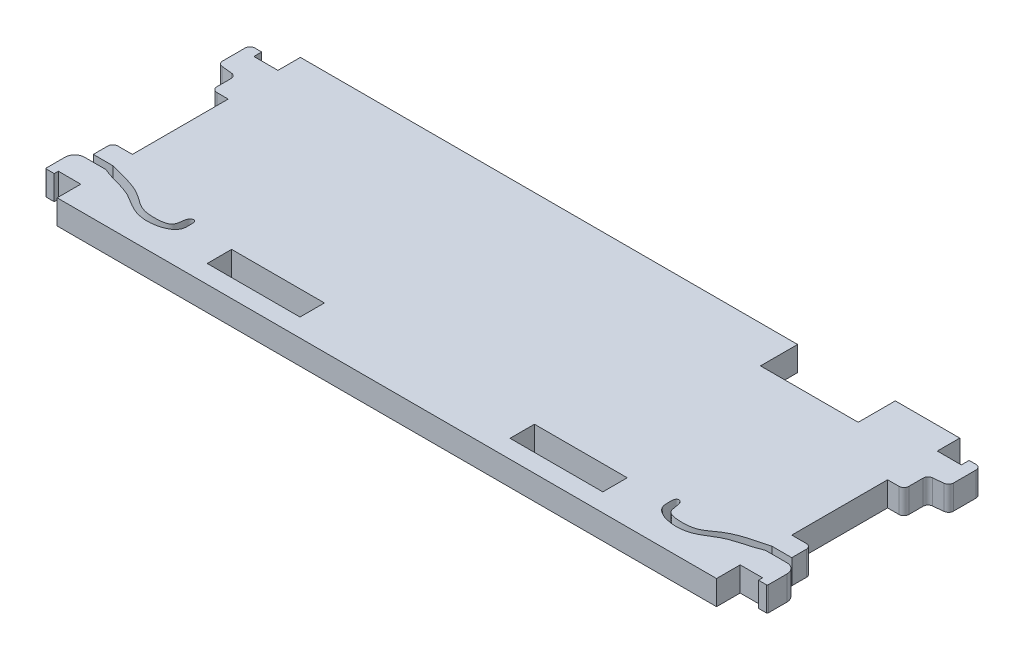
from build123d import *

# Parameters (mm, degrees)
SKETCH1_W           = 12.065
SKETCH1_H           = 3.175
BOSS_EXTRUDE1_DEPTH = 3.175


with BuildPart() as part:
    # Sketch1 → Boss-Extrude1 (new body)
    with BuildSketch(Plane(origin=(0, 0, 0), x_dir=(1, 0, 0), z_dir=(0, 1, 0))):
        with BuildLine():
            Line((34.4805, 15.8115), (34.4805, 10.9855))
            Line((34.4805, 10.9855), (21.7805, 10.9855))
            Line((21.7805, 10.9855), (21.7805, 15.8115))
            Line((21.7805, 15.8115), (-42.8625, 15.8115))
            Line((-42.8625, 15.8115), (-42.8625, 12.8905))
            Line((-42.8625, 12.8905), (-45.9867, 12.8905))
            Line((-45.9867, 12.8905), (-45.9867, 13.9065))
            Line((-45.9867, 13.9065), (-46.8757, 13.9065))
            ThreePointArc((-46.8757, 13.9065), (-47.324712806, 13.720512806), (-47.5107, 13.2715))
            Line((-47.5107, 13.2715), (-47.5107, 10.338056568))
            ThreePointArc((-47.5107, 10.338056568), (-47.347596964, 9.913158633), (-46.942075574, 9.706535165))
            Line((-46.942075574, 9.706535165), (-45.553238812, 9.560562539))
            ThreePointArc((-45.553238812, 9.560562539), (-45.147717422, 9.35393907), (-44.984614386, 8.929041135))
            Line((-44.984614386, 8.929041135), (-44.984614386, 7.062397703))
            ThreePointArc((-44.984614386, 7.062397703), (-44.798627192, 6.613384897), (-44.349614386, 6.427397703))
            Line((-44.349614386, 6.427397703), (-42.8625, 6.427397703))
            Line((-42.8625, 6.427397703), (-42.8625, -6.0325))
            Line((-42.8625, -6.0325), (-44.7675, -6.0325))
            ThreePointArc((-44.7675, -6.0325), (-45.216512806, -6.218487194), (-45.4025, -6.6675))
            Line((-45.4025, -6.6675), (-45.4025, -8.5725))
            Line((-45.4025, -8.5725), (-42.8625, -8.5725))
            add(Edge.make_bspline(
                [(-42.8625, -8.5725), (-41.235514661, -9.036919587), (-38.768416682, -9.43100007), (-36.286434981, -11.615283006), (-34.311523372, -11.820880416), (-32.159465718, -11.562671007), (-32.151870508, -10.227095557), (-31.90154009, -9.420959036), (-31.216693805, -9.360673169), (-31.153771417, -10.339051438), (-31.185927723, -11.920214415), (-33.996921582, -12.842750973), (-36.567382688, -12.305365627), (-39.155382597, -10.334194407), (-41.513606262, -10.077437392), (-42.8625, -9.4615)],
                knots=[0, 0, 0, 0, 0.185038788, 0.2600373, 0.34076905, 0.405570103, 0.445762007, 0.473510944, 0.483382171, 0.508842392, 0.552839679, 0.658674645, 0.754662587, 0.839418999, 1, 1, 1, 1], degree=3))
            Line((-42.8625, -9.4615), (-45.298270377, -9.4615))
            Line((-45.298270377, -9.4615), (-45.6565, -9.4615))
            ThreePointArc((-45.6565, -9.4615), (-46.554525612, -9.833474388), (-46.9265, -10.7315))
            Line((-46.9265, -10.7315), (-46.9265, -13.1445))
            ThreePointArc((-46.9265, -13.1445), (-46.889302561, -13.234302561), (-46.7995, -13.2715))
            Line((-46.7995, -13.2715), (-45.7835, -13.2715))
            Line((-45.7835, -13.2715), (-45.7835, -12.7381))
            Line((-45.7835, -12.7381), (-42.8625, -12.7381))
            Line((-42.8625, -12.7381), (-42.8625, -15.8115))
            Line((-42.8625, -15.8115), (42.8625, -15.8115))
            Line((42.8625, -15.8115), (42.8625, -12.7381))
            Line((42.8625, -12.7381), (45.7835, -12.7381))
            Line((45.7835, -12.7381), (45.7835, -13.2715))
            Line((45.7835, -13.2715), (46.7995, -13.2715))
            ThreePointArc((46.7995, -13.2715), (46.889302561, -13.234302561), (46.9265, -13.1445))
            Line((46.9265, -13.1445), (46.9265, -10.7315))
            ThreePointArc((46.9265, -10.7315), (46.554525612, -9.833474388), (45.6565, -9.4615))
            Line((45.6565, -9.4615), (45.298270377, -9.4615))
            Line((45.298270377, -9.4615), (42.8625, -9.4615))
            add(Edge.make_bspline(
                [(42.8625, -8.5725), (41.235514661, -9.036919587), (38.768416682, -9.43100007), (36.286434981, -11.615283006), (34.311523372, -11.820880416), (32.159465718, -11.562671007), (32.151870508, -10.227095557), (31.90154009, -9.420959036), (31.216693805, -9.360673169), (31.153771417, -10.339051438), (31.185927723, -11.920214415), (33.996921582, -12.842750973), (36.567382688, -12.305365627), (39.155382597, -10.334194407), (41.513606262, -10.077437392), (42.8625, -9.4615)],
                knots=[0, 0, 0, 0, 0.185038788, 0.2600373, 0.34076905, 0.405570103, 0.445762007, 0.473510944, 0.483382171, 0.508842392, 0.552839679, 0.658674645, 0.754662587, 0.839418999, 1, 1, 1, 1], degree=3))
            Line((42.8625, -8.5725), (45.4025, -8.5725))
            Line((45.4025, -8.5725), (45.4025, -6.6675))
            ThreePointArc((45.4025, -6.6675), (45.216512806, -6.218487194), (44.7675, -6.0325))
            Line((44.7675, -6.0325), (42.8625, -6.0325))
            Line((42.8625, -6.0325), (42.8625, 6.427397703))
            Line((42.8625, 6.427397703), (44.349614386, 6.427397703))
            ThreePointArc((44.349614386, 6.427397703), (44.798627192, 6.613384897), (44.984614386, 7.062397703))
            Line((44.984614386, 7.062397703), (44.984614386, 8.929041135))
            ThreePointArc((44.984614386, 8.929041135), (45.147717422, 9.35393907), (45.553238812, 9.560562539))
            Line((45.553238812, 9.560562539), (46.942075574, 9.706535165))
            ThreePointArc((46.942075574, 9.706535165), (47.347596964, 9.913158633), (47.5107, 10.338056568))
            Line((47.5107, 10.338056568), (47.5107, 13.2715))
            ThreePointArc((47.5107, 13.2715), (47.324712806, 13.720512806), (46.8757, 13.9065))
            Line((46.8757, 13.9065), (45.9867, 13.9065))
            Line((45.9867, 13.9065), (45.9867, 12.8905))
            Line((45.9867, 12.8905), (42.8625, 12.8905))
            Line((42.8625, 12.8905), (42.8625, 15.8115))
            Line((42.8625, 15.8115), (34.4805, 15.8115))
        make_face()
        with Locations((19.685, -11.8618)):
            Rectangle(SKETCH1_W, SKETCH1_H, mode=Mode.SUBTRACT)
        with Locations((-19.685, -11.8618)):
            Rectangle(SKETCH1_W, SKETCH1_H, mode=Mode.SUBTRACT)
    extrude(amount=BOSS_EXTRUDE1_DEPTH)


solid = part.part
